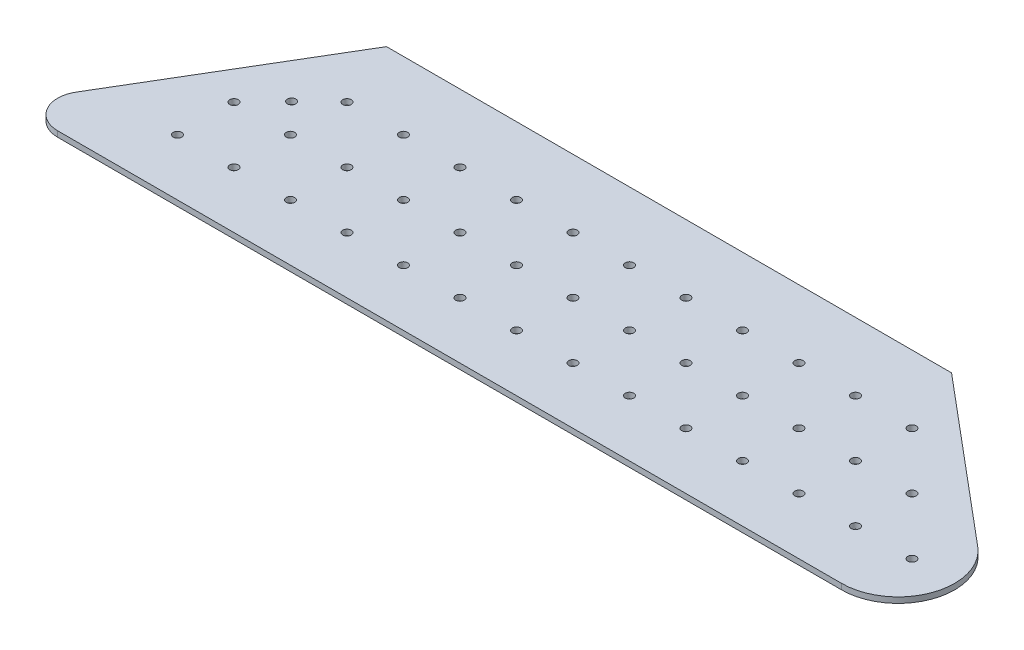
from build123d import *

# Parameters (mm, degrees)
SKETCH1_R           = 1.5
BOSS_EXTRUDE1_DEPTH = 2
FILLET4_R           = 20
FILLET5_R           = 10


with BuildPart() as part:
    # Sketch1 → Boss-Extrude1 (new body)
    with BuildSketch(Plane(origin=(0, 0, 0), x_dir=(1, 0, 0), z_dir=(0, 1, 0))):
        Polygon((-17.984046201, 0), (332.015953799, 0), (232.015953799, 84), (32.015953799, 84), align=None)
        with Locations((42.015953799, 20)):
            Circle(SKETCH1_R, mode=Mode.SUBTRACT)
        with Locations((62.015953799, 20)):
            Circle(SKETCH1_R, mode=Mode.SUBTRACT)
        with Locations((82.015953799, 20)):
            Circle(SKETCH1_R, mode=Mode.SUBTRACT)
        with Locations((102.015953799, 20)):
            Circle(SKETCH1_R, mode=Mode.SUBTRACT)
        with Locations((122.015953799, 20)):
            Circle(SKETCH1_R, mode=Mode.SUBTRACT)
        with Locations((22.015953799, 20)):
            Circle(SKETCH1_R, mode=Mode.SUBTRACT)
        with Locations((162.015953799, 20)):
            Circle(SKETCH1_R, mode=Mode.SUBTRACT)
        with Locations((182.015953799, 20)):
            Circle(SKETCH1_R, mode=Mode.SUBTRACT)
        with Locations((202.015953799, 20)):
            Circle(SKETCH1_R, mode=Mode.SUBTRACT)
        with Locations((222.015953799, 20)):
            Circle(SKETCH1_R, mode=Mode.SUBTRACT)
        with Locations((242.015953799, 20)):
            Circle(SKETCH1_R, mode=Mode.SUBTRACT)
        with Locations((142.015953799, 20)):
            Circle(SKETCH1_R, mode=Mode.SUBTRACT)
        with Locations((242.015953799, 60)):
            Circle(SKETCH1_R, mode=Mode.SUBTRACT)
        with Locations((222.015953799, 60)):
            Circle(SKETCH1_R, mode=Mode.SUBTRACT)
        with Locations((202.015953799, 60)):
            Circle(SKETCH1_R, mode=Mode.SUBTRACT)
        with Locations((182.015953799, 60)):
            Circle(SKETCH1_R, mode=Mode.SUBTRACT)
        with Locations((162.015953799, 60)):
            Circle(SKETCH1_R, mode=Mode.SUBTRACT)
        with Locations((142.015953799, 60)):
            Circle(SKETCH1_R, mode=Mode.SUBTRACT)
        with Locations((122.015953799, 60)):
            Circle(SKETCH1_R, mode=Mode.SUBTRACT)
        with Locations((102.015953799, 60)):
            Circle(SKETCH1_R, mode=Mode.SUBTRACT)
        with Locations((82.015953799, 60)):
            Circle(SKETCH1_R, mode=Mode.SUBTRACT)
        with Locations((62.015953799, 60)):
            Circle(SKETCH1_R, mode=Mode.SUBTRACT)
        with Locations((42.015953799, 60)):
            Circle(SKETCH1_R, mode=Mode.SUBTRACT)
        with Locations((282.015953799, 20)):
            Circle(SKETCH1_R, mode=Mode.SUBTRACT)
        with Locations((262.015953799, 20)):
            Circle(SKETCH1_R, mode=Mode.SUBTRACT)
        with Locations((262.015953799, 40)):
            Circle(SKETCH1_R, mode=Mode.SUBTRACT)
        with Locations((242.015953799, 40)):
            Circle(SKETCH1_R, mode=Mode.SUBTRACT)
        with Locations((202.015953799, 40)):
            Circle(SKETCH1_R, mode=Mode.SUBTRACT)
        with Locations((182.015953799, 40)):
            Circle(SKETCH1_R, mode=Mode.SUBTRACT)
        with Locations((162.015953799, 40)):
            Circle(SKETCH1_R, mode=Mode.SUBTRACT)
        with Locations((142.015953799, 40)):
            Circle(SKETCH1_R, mode=Mode.SUBTRACT)
        with Locations((122.015953799, 40)):
            Circle(SKETCH1_R, mode=Mode.SUBTRACT)
        with Locations((102.015953799, 40)):
            Circle(SKETCH1_R, mode=Mode.SUBTRACT)
        with Locations((82.015953799, 40)):
            Circle(SKETCH1_R, mode=Mode.SUBTRACT)
        with Locations((62.015953799, 40)):
            Circle(SKETCH1_R, mode=Mode.SUBTRACT)
        with Locations((42.015953799, 40)):
            Circle(SKETCH1_R, mode=Mode.SUBTRACT)
        with Locations((22.015953799, 40)):
            Circle(SKETCH1_R, mode=Mode.SUBTRACT)
        with Locations((222.015953799, 40)):
            Circle(SKETCH1_R, mode=Mode.SUBTRACT)
        with Locations((32.015953799, 50.397368307)):
            Circle(SKETCH1_R, mode=Mode.SUBTRACT)
    extrude(amount=BOSS_EXTRUDE1_DEPTH)

    # Fillet4
    fillet4_edges = [part.edges().sort_by_distance(p)[0] for p in [
        (332.015953799, 1, 0),
    ]]
    fillet(fillet4_edges, radius=FILLET4_R)

    # Fillet5
    fillet5_edges = [part.edges().sort_by_distance(p)[0] for p in [
        (-17.984046201, 1, 0),
    ]]
    fillet(fillet5_edges, radius=FILLET5_R)


solid = part.part
